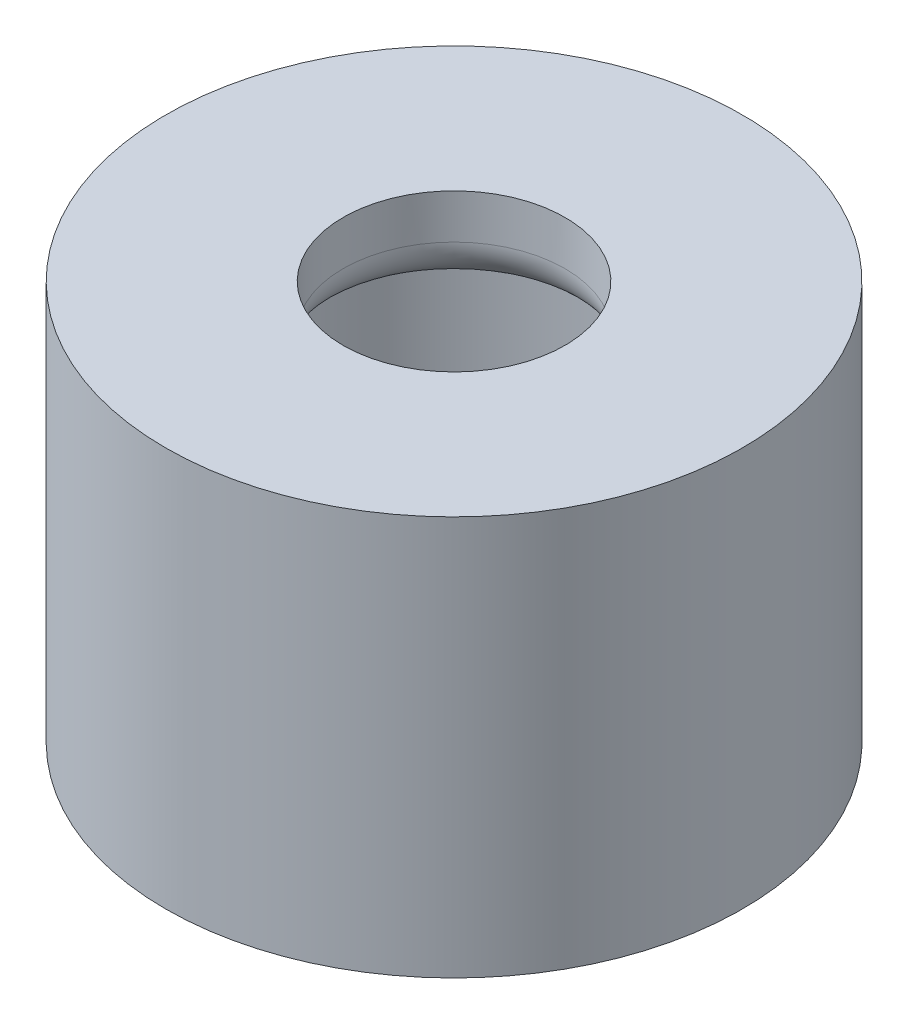
from build123d import *

# Parameters (mm, degrees)
SKETCH1_R           = 6.5
BOSS_EXTRUDE1_DEPTH = 9
SKETCH3_R           = 4.5
CUT_EXTRUDE1_DEPTH  = 7
SKETCH2_R           = 2.5
CUT_EXTRUDE2_DEPTH  = 3
FILLET2_R           = 1


with BuildPart() as part:
    # Sketch1 → Boss-Extrude1 (new body)
    with BuildSketch(Plane(origin=(0, 0, 0), x_dir=(1, 0, 0), z_dir=(0, 1, 0))):
        Circle(SKETCH1_R)
    extrude(amount=BOSS_EXTRUDE1_DEPTH)

    # Sketch3 → Cut-Extrude1 (cut)
    with BuildSketch(Plane.XZ):
        Circle(SKETCH3_R)
    extrude(amount=-CUT_EXTRUDE1_DEPTH, mode=Mode.SUBTRACT)

    # Sketch2 → Cut-Extrude2 (cut)
    with BuildSketch(Plane(origin=(0, 9, 0), x_dir=(1, 0, 0), z_dir=(0, 1, 0))):
        Circle(SKETCH2_R)
    extrude(amount=-CUT_EXTRUDE2_DEPTH, mode=Mode.SUBTRACT)

    # Fillet2
    fillet2_edges = [part.edges().sort_by_distance(p)[0] for p in [
        (-2.5, 7, 0),
    ]]
    fillet(fillet2_edges, radius=FILLET2_R)


solid = part.part
